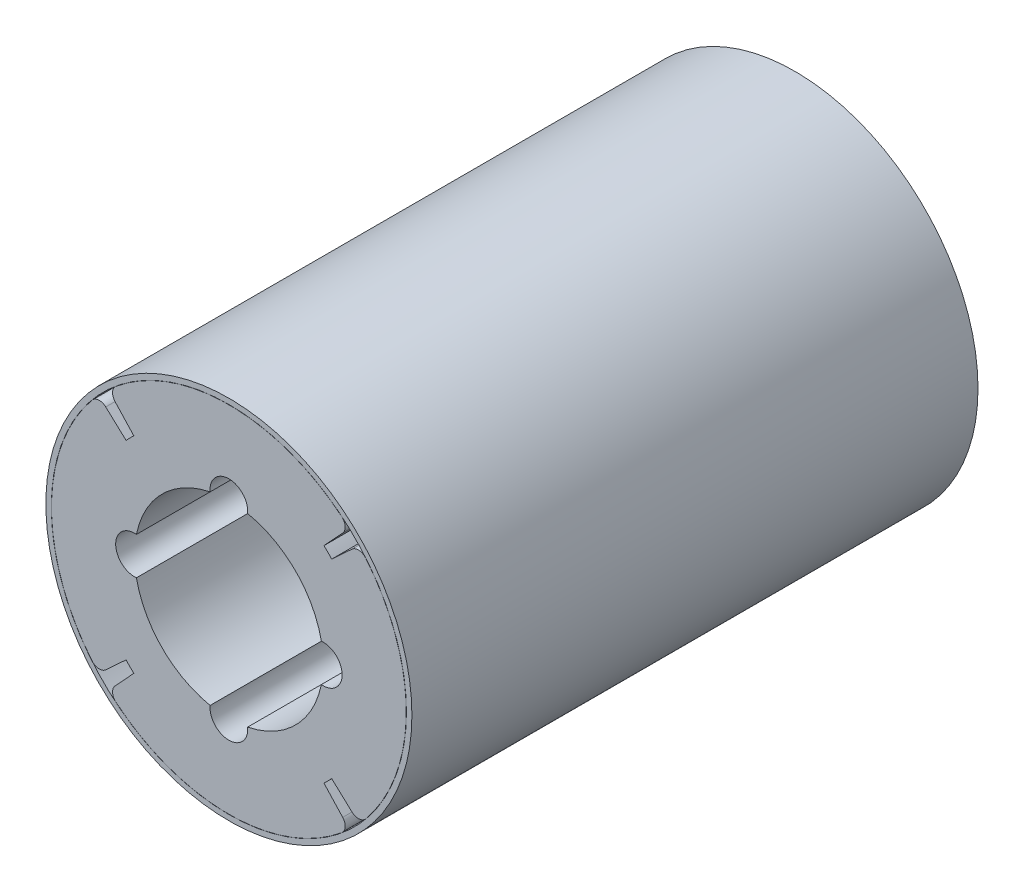
from build123d import *

# Parameters (mm, degrees)
SKETCH1_R           = 7.42
SKETCH1_R_2         = 5
BOSS_EXTRUDE1_DEPTH = 30
BOSS_EXTRUDE2_DEPTH = 30
CIRPATTERN1_COUNT   = 4
SKETCH3_R           = 9.7
SKETCH3_R_2         = 9.41
BOSS_EXTRUDE3_DEPTH = 30
SKETCH4_R           = 1
CUT_EXTRUDE2_DEPTH  = 30
CIRPATTERN2_COUNT   = 4


with BuildPart() as part:
    # Sketch1 → Boss-Extrude1 (new body)
    with BuildSketch(Plane.XY):
        Circle(SKETCH1_R)
        Circle(SKETCH1_R_2, mode=Mode.SUBTRACT)
    extrude(amount=BOSS_EXTRUDE1_DEPTH)

    # Sketch2 → Boss-Extrude2 (add)
    with BuildSketch(Plane.XY):
        with BuildLine():
            Line((5.036701532, 5.44867302), (6.031785383, 6.525148665))
            ThreePointArc((6.031785383, 6.525148665), (6.163489723, 6.898210854), (5.982861438, 7.25019786))
            ThreePointArc((5.982861438, 7.25019786), (0, 9.4), (-5.982861438, 7.25019786))
            ThreePointArc((-5.982861438, 7.25019786), (-6.163489723, 6.898210854), (-6.031785383, 6.525148665))
            Line((-6.031785383, 6.525148665), (-5.036701532, 5.44867302))
            ThreePointArc((-5.036701532, 5.44867302), (0, 7.42), (5.036701532, 5.44867302))
        make_face()
    boss_extrude2 = extrude(amount=BOSS_EXTRUDE2_DEPTH)

    # CirPattern1: Boss-Extrude2 ×4 about axis
    cirpattern1_axis = Axis((0, 0, 0), (0, 0, 1))
    for i in range(1, CIRPATTERN1_COUNT):
        add(boss_extrude2.rotate(cirpattern1_axis, i * 360 / CIRPATTERN1_COUNT))

    # Sketch4 → Cut-Extrude2 (cut)
    with BuildSketch(Plane.XY):
        with Locations((0, 5)):
            Circle(SKETCH4_R)
    cut_extrude2 = extrude(amount=CUT_EXTRUDE2_DEPTH, mode=Mode.SUBTRACT)

    # CirPattern2: Cut-Extrude2 ×4 about axis
    cirpattern2_axis = Axis((0, 0, 0), (0, 0, 1))
    for i in range(1, CIRPATTERN2_COUNT):
        add(cut_extrude2.rotate(cirpattern2_axis, i * 360 / CIRPATTERN2_COUNT), mode=Mode.SUBTRACT)


with BuildPart() as body_2:
    # Sketch3 → Boss-Extrude3 (new body)
    with BuildSketch(Plane.XY):
        Circle(SKETCH3_R)
        Circle(SKETCH3_R_2, mode=Mode.SUBTRACT)
    extrude(amount=BOSS_EXTRUDE3_DEPTH)


solid = Compound([part.part, body_2.part])
